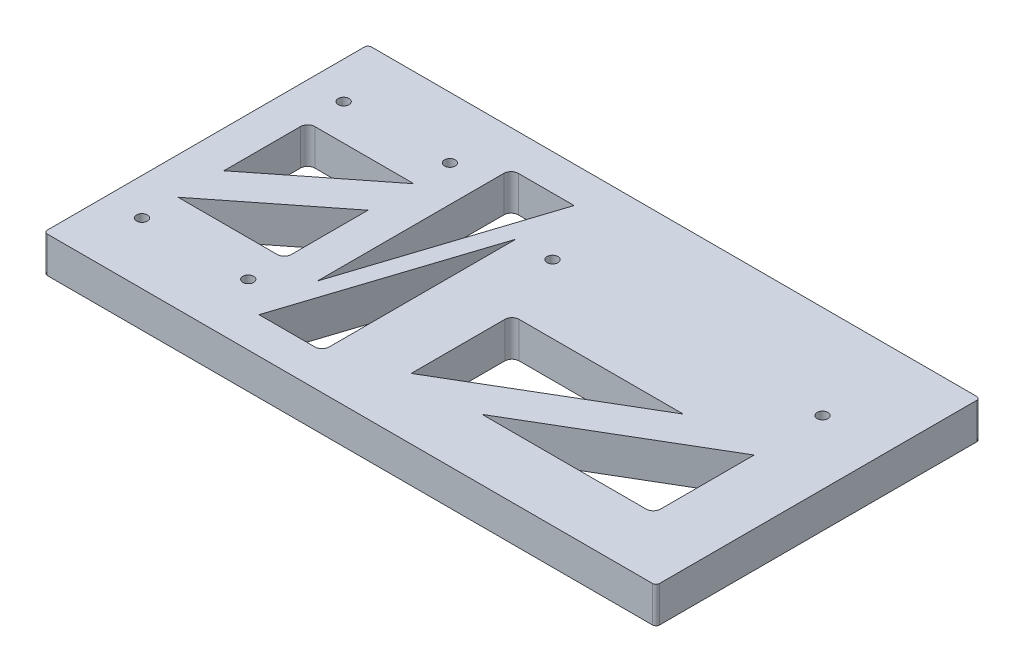
from build123d import *

# Parameters (mm, degrees)
SKETCH1_W           = 170
SKETCH1_H           = 90
BOSS_EXTRUDE1_DEPTH = 10
SKETCH2_R           = 1.5
CUT_EXTRUDE1_DEPTH  = 97.695398029
FILLET1_R           = 1
SKETCH2_9_R         = 1.5
CUT_EXTRUDE2_DEPTH  = 97.695398029
CUT_EXTRUDE3_DEPTH  = 97.695398029
FILLET3_R           = 2


with BuildPart() as part:
    # Sketch1 → Boss-Extrude1 (new body)
    with BuildSketch(Plane(origin=(0, 0, 0), x_dir=(1, 0, 0), z_dir=(0, 1, 0))):
        Rectangle(SKETCH1_W, SKETCH1_H)
    extrude(amount=BOSS_EXTRUDE1_DEPTH)

    # Sketch2 → Cut-Extrude1 (cut, through all)
    with BuildSketch(Plane(origin=(0, 10, 0), x_dir=(1, 0, 0), z_dir=(0, 1, 0))):
        with Locations((-74.75, -28)):
            Circle(SKETCH2_R)
        with Locations((-45.25, -28)):
            Circle(SKETCH2_R)
    cut_extrude1 = extrude(amount=-CUT_EXTRUDE1_DEPTH, mode=Mode.SUBTRACT)

    # Mirror1: Cut-Extrude1 across plane
    add(cut_extrude1.mirror(Plane.XY), mode=Mode.SUBTRACT)

    # Fillet1
    fillet1_edges = [part.edges().sort_by_distance(p)[0] for p in [
        (-85, 5, -45),
        (85, 5, -45),
        (85, 5, 45),
        (-85, 5, 45),
    ]]
    fillet(fillet1_edges, radius=FILLET1_R)

    # Sketch2_9 → Cut-Extrude2 (cut, through all)
    with BuildSketch(Plane(origin=(0, 10, 0), x_dir=(1, 0, 0), z_dir=(0, 1, 0))):
        with Locations((-7.75, 19)):
            Circle(SKETCH2_9_R)
        with Locations((67.25, 19)):
            Circle(SKETCH2_9_R)
    extrude(amount=-CUT_EXTRUDE2_DEPTH, mode=Mode.SUBTRACT)

    # Sketch3 → Cut-Extrude3 (cut, through all)
    with BuildSketch(Plane(origin=(0, 10, 0), x_dir=(1, 0, 0), z_dir=(0, 1, 0))):
        Polygon((0, 0), (0, -28), (47.544117112, 0), align=None)
        Polygon((67.25, 0), (19.705882888, -28), (67.25, -28), align=None)
        Polygon((-35.25, -35), (-17.75, -35), (-17.75, 18.828164368), align=None)
        Polygon((-35.25, 35), (-35.25, -18.828164368), (-17.75, 35), align=None)
        Polygon((-74.75, -18), (-45.25, -18), (-45.25, 5.264489844), align=None)
        Polygon((-74.75, 18), (-74.75, -5.264489844), (-45.25, 18), align=None)
    extrude(amount=-CUT_EXTRUDE3_DEPTH, mode=Mode.SUBTRACT)

    # Fillet3
    fillet3_edges = [part.edges().sort_by_distance(p)[0] for p in [
        (-17.75, 5, 35),
        (-35.25, 5, -35),
        (67.25, 5, 28),
        (0, 5, 0),
        (-74.75, 5, -18),
        (-45.25, 5, 18),
    ]]
    fillet(fillet3_edges, radius=FILLET3_R)


solid = part.part
